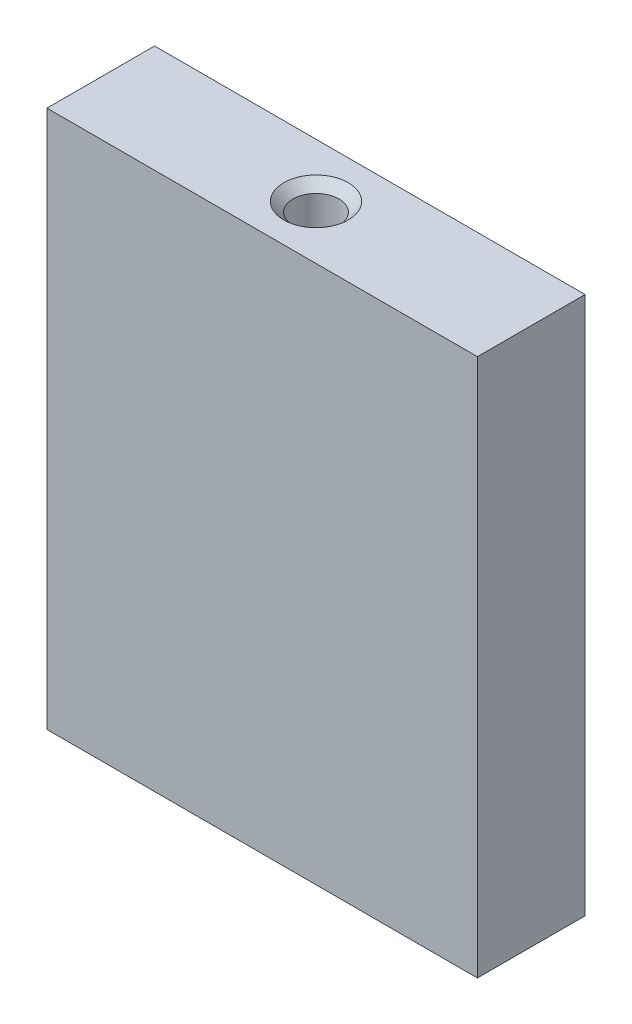
from build123d import *

# Parameters (mm, degrees)
SKETCH1_W           = 50.8
SKETCH1_H           = 12.7
BOSS_EXTRUDE1_DEPTH = 31.75


with BuildPart() as part:
    # Sketch1 → Boss-Extrude1 (new body, symmetric)
    with BuildSketch(Plane(origin=(0, 0, 0), x_dir=(1, 0, 0), z_dir=(0, 1, 0))):
        Rectangle(SKETCH1_W, SKETCH1_H)
    extrude(amount=BOSS_EXTRUDE1_DEPTH, both=True)

    # Sketch3 → 1/4-28 Tapped Hole1 (revolve, cut)
    with BuildSketch(Plane(origin=(0, 31.75, 0), x_dir=(0, 0, 1), z_dir=(1, 0, 0))):
        Polygon((0, 0), (0, 7.975388061), (2.7051, 6.35), (2.7051, 1.1049), (3.81, 0), align=None)
    f_1_4_28_tapped_hole1 = revolve(axis=Axis((0, 38.1, 0), (0, -1, 0)), mode=Mode.SUBTRACT)

    # Mirror1: 1/4-28 Tapped Hole1 across plane
    add(f_1_4_28_tapped_hole1.mirror(Plane.ZX), mode=Mode.SUBTRACT)


solid = part.part
